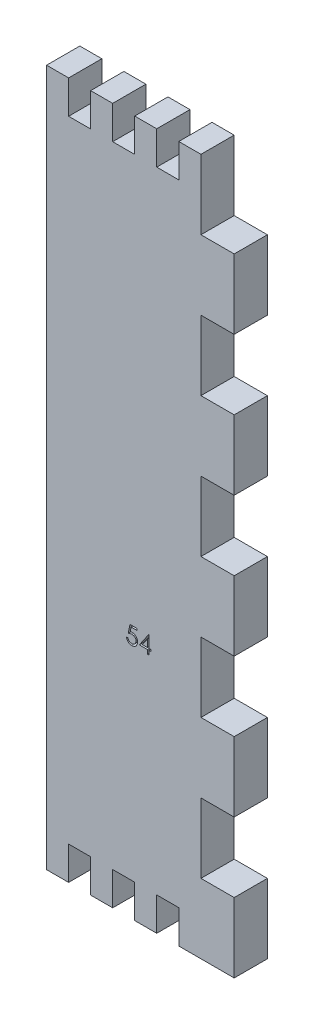
from build123d import *

# Parameters (mm, degrees)
BOSS_EXTRUDE7_DEPTH = 6.2
CUT_EXTRUDE10_DEPTH = 1


with BuildPart() as part:
    # Sketch1 → Boss-Extrude7 (new body)
    with BuildSketch(Plane.XY):
        Polygon((4.11, 130), (0, 130), (0, 0), (4.11, 0), (4.11, 6.2), (8.22, 6.2), (8.22, 0), (12.33, 0), (12.33, 6.2), (16.44, 6.2), (16.44, 0), (20.55, 0), (20.55, 6.2), (24.66, 6.2), (24.66, 0), (35, 0), (35, 13), (28.8, 13), (28.8, 26), (35, 26), (35, 39), (28.8, 39), (28.8, 52), (35, 52), (35, 65), (28.8, 65), (28.8, 78), (35, 78), (35, 91), (28.8, 91), (28.8, 104), (35, 104), (35, 117), (28.8, 117), (28.8, 130), (24.66, 130), (24.66, 123.8), (20.55, 123.8), (20.55, 130), (16.44, 130), (16.44, 123.8), (12.33, 123.8), (12.33, 130), (8.22, 130), (8.22, 123.8), (4.11, 123.8), align=None)
    extrude(amount=BOSS_EXTRUDE7_DEPTH)

    # Sketch7 → Cut-Extrude10 (cut)
    with BuildSketch(Plane.XY.offset(6.2)):
        with BuildLine():
            Line((16.852728424, 47.419269681), (16.852728424, 47.093628655))
            Line((16.852728424, 47.093628655), (15.772770491, 47.093628655))
            Line((15.772770491, 47.093628655), (15.601681749, 46.25853751))
            add(Edge.make_bspline(
                [(15.601681749, 46.25853751), (15.635296721, 46.267817828), (15.700420412, 46.285796976), (15.796541143, 46.305759353), (15.887792642, 46.317793006), (15.947006728, 46.319436124), (15.975660115, 46.32023122)],
                knots=[0, 0, 0, 0, 0.000104595, 0.000202637, 0.000294305, 0.000380252, 0.000380252, 0.000380252, 0.000380252], degree=3))
            add(Edge.make_bspline(
                [(15.975660115, 46.32023122), (16.01111465, 46.319463835), (16.080827125, 46.317954965), (16.182825312, 46.303466216), (16.28019158, 46.280660722), (16.372722301, 46.248801392), (16.460588658, 46.208061848), (16.542982232, 46.157171188), (16.621139767, 46.097723095), (16.69365912, 46.029374405), (16.759449028, 45.954152653), (16.81729389, 45.873273727), (16.866427097, 45.787523633), (16.905942925, 45.696083081), (16.937497285, 45.599962992), (16.958499452, 45.498152006), (16.972484609, 45.391609783), (16.97404706, 45.318762066), (16.974843809, 45.281614433)],
                knots=[0, 0, 0, 0, 0.000106308, 0.000209029, 0.000308378, 0.000405929, 0.000502102, 0.000598312, 0.00069588, 0.000796219, 0.000896736, 0.000995218, 0.001094066, 0.001192613, 0.001293582, 0.001396995, 0.001504047, 0.001615439, 0.001615439, 0.001615439, 0.001615439], degree=3))
            add(Edge.make_bspline(
                [(16.974843809, 45.281614433), (16.97424049, 45.255740704), (16.973042007, 45.204342908), (16.966947288, 45.128012098), (16.955212746, 45.053297242), (16.939457739, 44.980188429), (16.919008546, 44.90882407), (16.894253475, 44.838999899), (16.863958507, 44.771150505), (16.830728617, 44.704633897), (16.793312169, 44.640953823), (16.751784523, 44.581400813), (16.707910113, 44.525081501), (16.660701142, 44.4725999), (16.609718811, 44.424300877), (16.555580555, 44.379897793), (16.498718374, 44.338639729), (16.438252547, 44.302201438), (16.375530438, 44.268670756), (16.309646269, 44.241162976), (16.242099777, 44.216569854), (16.171918783, 44.196966925), (16.099262253, 44.181606679), (16.024010421, 44.171173992), (15.946557956, 44.163575366), (15.894057051, 44.1630997), (15.867537118, 44.162859425)],
                knots=[0, 0, 0, 0, 7.7636e-05, 0.000154223, 0.000229512, 0.000304362, 0.000378447, 0.000452077, 0.000526407, 0.000601214, 0.00067506, 0.000747747, 0.00081887, 0.000889121, 0.000959302, 0.001029336, 0.001099058, 0.00116985, 0.001240974, 0.00131221, 0.00138383, 0.001456517, 0.001530612, 0.001606437, 0.001684346, 0.001763871, 0.001763871, 0.001763871, 0.001763871], degree=3))
            add(Edge.make_bspline(
                [(15.867537118, 44.162859425), (15.835901254, 44.163486113), (15.773661429, 44.164719049), (15.682474915, 44.177617247), (15.594740951, 44.196090228), (15.511165788, 44.223881701), (15.431000427, 44.258704462), (15.355324104, 44.30271556), (15.28220315, 44.352589461), (15.214610088, 44.41144521), (15.151875614, 44.475775865), (15.095717567, 44.545587439), (15.045703536, 44.619727719), (15.002634437, 44.698556758), (14.965896947, 44.781867426), (14.937036207, 44.869971862), (14.913742271, 44.962409723), (14.903887597, 45.026048979), (14.89888227, 45.058372245)],
                knots=[0, 0, 0, 0, 9.4843e-05, 0.000186593, 0.000275792, 0.000363484, 0.000450342, 0.000537514, 0.000625728, 0.000715478, 0.000805885, 0.000894984, 0.00098389, 0.001073836, 0.001164117, 0.001256635, 0.001351658, 0.001449737, 0.001449737, 0.001449737, 0.001449737], degree=3))
            Line((14.89888227, 45.058372245), (15.183818168, 45.058372245))
            add(Edge.make_bspline(
                [(15.183818168, 45.058372245), (15.190829073, 45.028095035), (15.204304423, 44.969900555), (15.233882495, 44.888138553), (15.270046539, 44.815277543), (15.313049055, 44.750353706), (15.364348012, 44.69373983), (15.422885422, 44.64328721), (15.488515143, 44.5977712), (15.561443286, 44.559831975), (15.638380866, 44.52747532), (15.718905406, 44.50592914), (15.800824349, 44.490779044), (15.856231156, 44.489262518), (15.884073576, 44.48850045)],
                knots=[0, 0, 0, 0, 9.3172e-05, 0.000179081, 0.000260145, 0.000336703, 0.000411917, 0.000488562, 0.000568128, 0.000650923, 0.00073478, 0.000817953, 0.000900557, 0.000983994, 0.000983994, 0.000983994, 0.000983994], degree=3))
            add(Edge.make_bspline(
                [(15.884073576, 44.48850045), (15.911250165, 44.489245013), (15.964761091, 44.490711063), (16.04351142, 44.501995024), (16.11954167, 44.519373678), (16.19210163, 44.545381332), (16.262461026, 44.57699047), (16.32884009, 44.617553432), (16.393159128, 44.66423502), (16.453418935, 44.717717106), (16.508609007, 44.7766539), (16.557373488, 44.839679821), (16.597992545, 44.906914389), (16.632222773, 44.977193606), (16.658215408, 45.051287726), (16.676758298, 45.128849506), (16.687646787, 45.210070524), (16.689144643, 45.265469112), (16.689907911, 45.293698768)],
                knots=[0, 0, 0, 0, 8.15e-05, 0.000160473, 0.000238226, 0.000315066, 0.000391338, 0.000469218, 0.000547964, 0.000629516, 0.000710512, 0.000789892, 0.000868102, 0.000945761, 0.001024012, 0.00110315, 0.001184644, 0.001269321, 0.001269321, 0.001269321, 0.001269321], degree=3))
            add(Edge.make_bspline(
                [(16.689907911, 45.293698768), (16.689310576, 45.319167485), (16.688141378, 45.369018876), (16.678588646, 45.441952442), (16.661972536, 45.510961559), (16.638909445, 45.576379471), (16.60962732, 45.638267879), (16.573843879, 45.696690655), (16.530887583, 45.750877776), (16.481818512, 45.800854592), (16.428063004, 45.846978157), (16.36869618, 45.886297436), (16.304960389, 45.919375418), (16.237623538, 45.947921388), (16.165083952, 45.968423493), (16.08877815, 45.983815789), (16.007882136, 45.992719725), (15.952573012, 45.993955152), (15.924142687, 45.994590194)],
                knots=[0, 0, 0, 0, 7.6388e-05, 0.000149519, 0.000220172, 0.000288967, 0.000357247, 0.000425206, 0.000494043, 0.000564207, 0.000635056, 0.000706145, 0.000777268, 0.000850264, 0.000925136, 0.001002969, 0.001083601, 0.001168886, 0.001168886, 0.001168886, 0.001168886], degree=3))
            add(Edge.make_bspline(
                [(15.924142687, 45.994590194), (15.899532873, 45.994063515), (15.84871985, 45.992976056), (15.770775572, 45.984969162), (15.68886808, 45.972052088), (15.603311359, 45.954284564), (15.51384847, 45.931033516), (15.420668206, 45.903171076), (15.32357465, 45.869858977), (15.258153572, 45.844701897), (15.224523296, 45.831769681)],
                knots=[0, 0, 0, 0, 7.3822e-05, 0.000152423, 0.000234822, 0.000322511, 0.00041445, 0.000512043, 0.000614219, 0.000722306, 0.000722306, 0.000722306, 0.000722306], degree=3))
            Line((15.224523296, 45.831769681), (15.550164321, 47.419269681))
            Line((15.550164321, 47.419269681), (16.852728424, 47.419269681))
        make_face()
        Polygon((19.033632871, 47.500679937), (19.091510475, 47.500679937), (19.091510475, 45.302603014), (19.457856629, 45.302603014), (19.457856629, 44.976961989), (19.091510475, 44.976961989), (19.091510475, 44.244269681), (18.806574578, 44.244269681), (18.806574578, 44.976961989), (17.300484834, 44.976961989), align=None)
        Polygon((18.806574578, 45.302603014), (18.806574578, 46.681489232), (17.860180347, 45.302603014), align=None, mode=Mode.SUBTRACT)
    extrude(amount=-CUT_EXTRUDE10_DEPTH, mode=Mode.SUBTRACT)


solid = part.part
